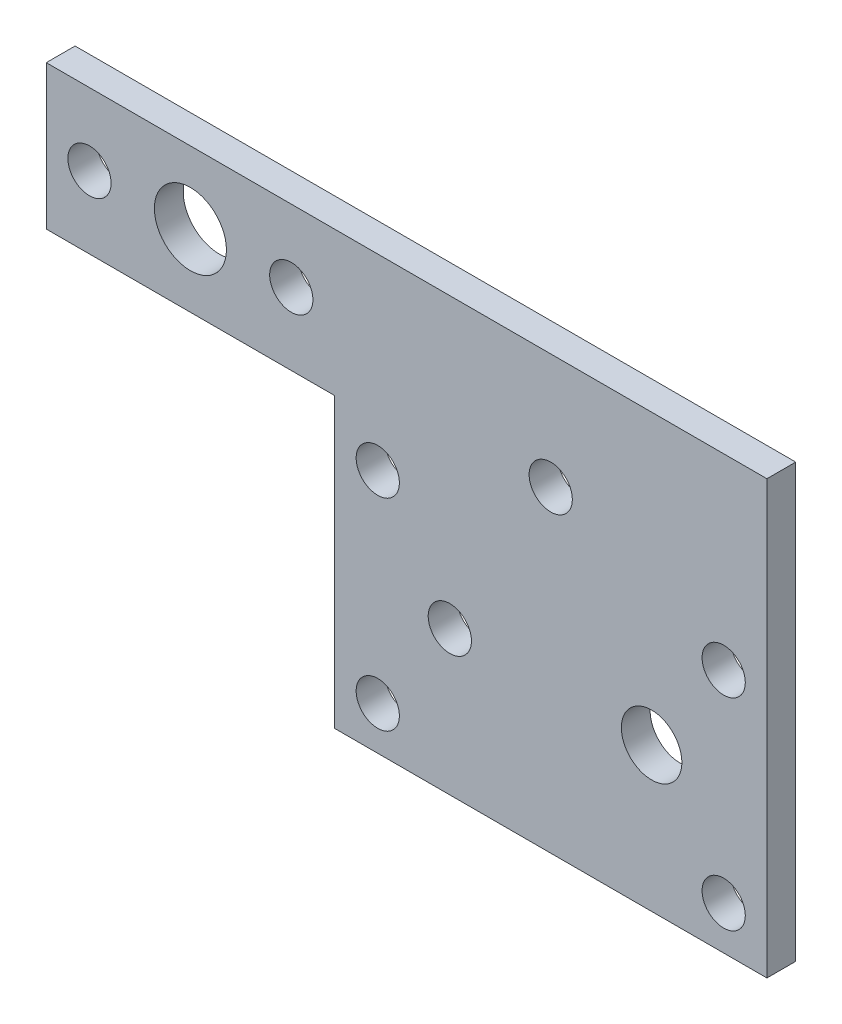
from build123d import *

# Parameters (mm, degrees)
SKETCH1_R           = 1.5
SKETCH1_R_2         = 2.1
SKETCH1_R_3         = 2.5
BOSS_EXTRUDE1_DEPTH = 2


with BuildPart() as part:
    # Sketch1 → Boss-Extrude1 (new body)
    with BuildSketch(Plane.XY):
        Polygon((20, 0), (50, 0), (50, 30), (0, 30), (0, 20), (20, 20), align=None)
        with Locations((23, 17)):
            Circle(SKETCH1_R, mode=Mode.SUBTRACT)
        with Locations((23, 3)):
            Circle(SKETCH1_R, mode=Mode.SUBTRACT)
        with Locations((47, 3)):
            Circle(SKETCH1_R, mode=Mode.SUBTRACT)
        with Locations((47, 17)):
            Circle(SKETCH1_R, mode=Mode.SUBTRACT)
        with Locations((3, 25)):
            Circle(SKETCH1_R, mode=Mode.SUBTRACT)
        with Locations((17, 25)):
            Circle(SKETCH1_R, mode=Mode.SUBTRACT)
        with Locations((28, 10)):
            Circle(SKETCH1_R, mode=Mode.SUBTRACT)
        with Locations((35, 22)):
            Circle(SKETCH1_R, mode=Mode.SUBTRACT)
        with Locations((42, 10)):
            Circle(SKETCH1_R_2, mode=Mode.SUBTRACT)
        with Locations((10, 25)):
            Circle(SKETCH1_R_3, mode=Mode.SUBTRACT)
    extrude(amount=BOSS_EXTRUDE1_DEPTH)


solid = part.part
